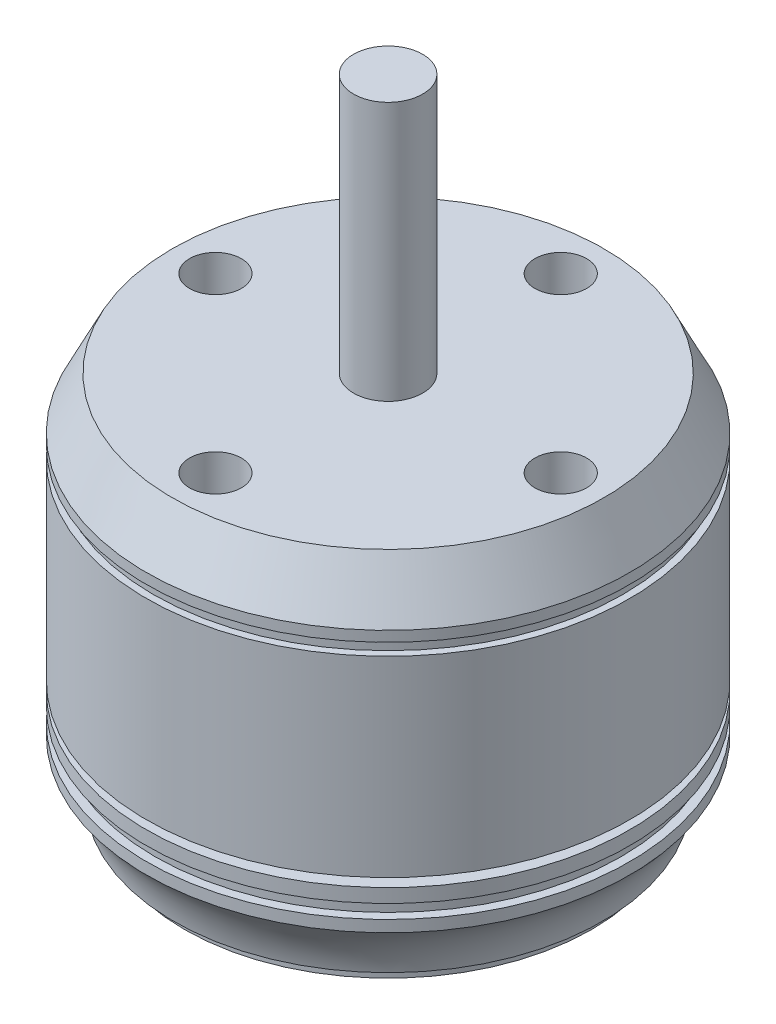
from build123d import *

# Parameters (mm, degrees)
SKETCH2_R          = 1.5
CUT_EXTRUDE1_DEPTH = 3
SKETCH3_R          = 1.5
CUT_EXTRUDE2_DEPTH = 2.8


with BuildPart() as part:
    # Sketch1 → Revolve1 (revolve)
    with BuildSketch(Plane.XY):
        with BuildLine():
            Line((0, 0), (11.8, 0))
            Line((11.8, 0), (11.8, 0.7))
            Line((11.8, 0.7), (12.4, 0.7))
            ThreePointArc((12.4, 0.7), (12.965636633, 2.38480236), (14, 3.83))
            Line((14, 3.83), (14, 4.5))
            Line((14, 4.5), (13.5, 4.5))
            Line((13.5, 4.5), (13.5, 5.3))
            Line((13.5, 5.3), (14, 5.3))
            Line((14, 5.3), (14, 6.1))
            Line((14, 6.1), (2, 6.1))
            Line((2, 6.1), (2, 6.6))
            Line((2, 6.6), (14, 6.6))
            Line((14, 6.6), (14, 17.7))
            Line((14, 17.7), (13.6, 17.7))
            Line((13.6, 17.7), (13.6, 18.4))
            Line((13.6, 18.4), (14, 18.4))
            Line((14, 18.4), (14, 19))
            Line((14, 19), (12.5, 22))
            Line((12.5, 22), (2, 22))
            Line((2, 22), (2, 37))
            Line((2, 37), (0, 37))
            Line((0, 37), (0, 0))
        make_face()
    revolve(axis=Axis((0, 37, 0), (0, -1, 0)))

    # Sketch2 → Cut-Extrude1 (cut)
    with BuildSketch(Plane.XZ):
        with Locations((0, 8)):
            Circle(SKETCH2_R)
        with Locations((9.5, 0)):
            Circle(SKETCH2_R)
        with Locations((0, -8)):
            Circle(SKETCH2_R)
        with Locations((-9.5, 0)):
            Circle(SKETCH2_R)
    extrude(amount=-CUT_EXTRUDE1_DEPTH, mode=Mode.SUBTRACT)

    # Sketch3 → Cut-Extrude2 (cut)
    with BuildSketch(Plane(origin=(0, 22, 0), x_dir=(1, 0, 0), z_dir=(0, 1, 0))):
        with Locations((0, 10)):
            Circle(SKETCH3_R)
        with Locations((10, 0)):
            Circle(SKETCH3_R)
        with Locations((0, -10)):
            Circle(SKETCH3_R)
        with Locations((-10, 0)):
            Circle(SKETCH3_R)
    extrude(amount=-CUT_EXTRUDE2_DEPTH, mode=Mode.SUBTRACT)


solid = part.part
